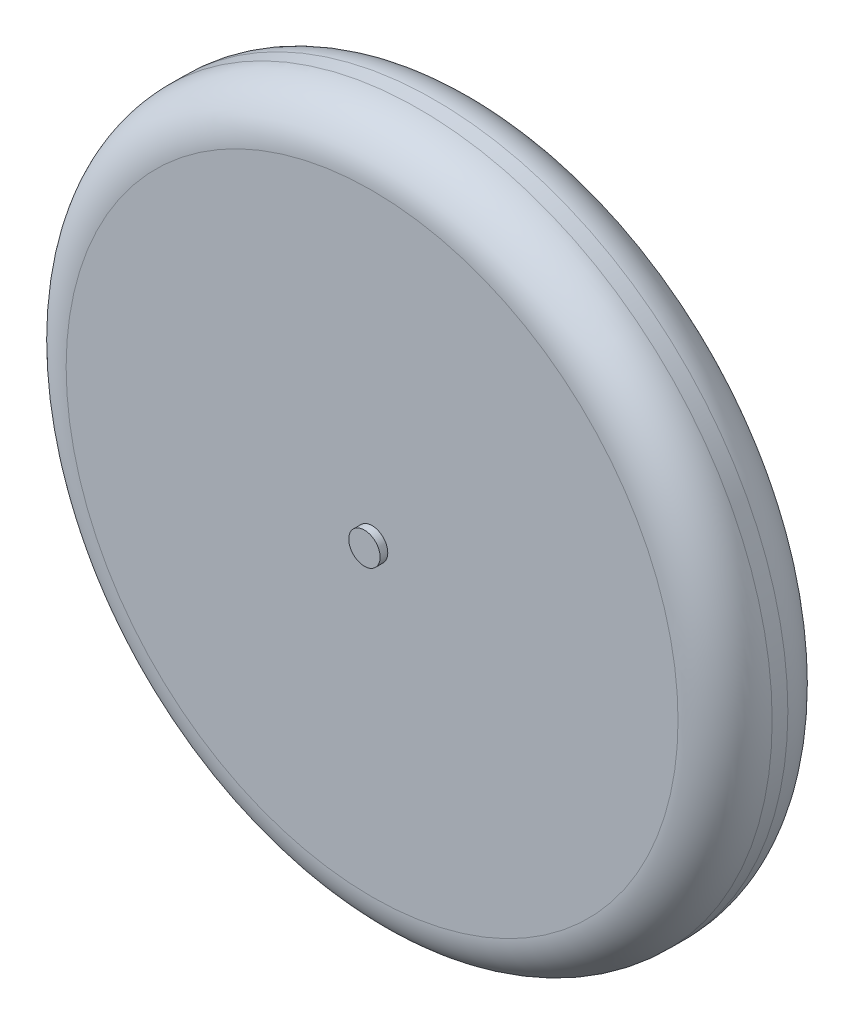
from build123d import *


with BuildPart() as part:
    # Sketch1 → Revolve1 (revolve)
    with BuildSketch(Plane(origin=(0, 0, 0), x_dir=(1, 0, 0), z_dir=(0, 1, 0))):
        with BuildLine():
            Line((0, 0), (2.54, 0))
            Line((2.54, 0), (2.54, -1.239469248))
            Line((2.54, -1.239469248), (49.53, -1.239469248))
            ThreePointArc((49.53, -1.239469248), (54.918153673, -3.471315575), (57.15, -8.859469248))
            Line((57.15, -8.859469248), (57.15, -11.399469248))
            ThreePointArc((57.15, -11.399469248), (54.918153673, -16.787622921), (49.53, -19.019469248))
            Line((49.53, -19.019469248), (2.54, -19.019469248))
            Line((2.54, -19.019469248), (2.54, -20.258938496))
            Line((2.54, -20.258938496), (0, -20.258938496))
            Line((0, -20.258938496), (0, 0))
        make_face()
    revolve(axis=Axis((0, 0, 20.258938496), (0, 0, -1)))


solid = part.part
